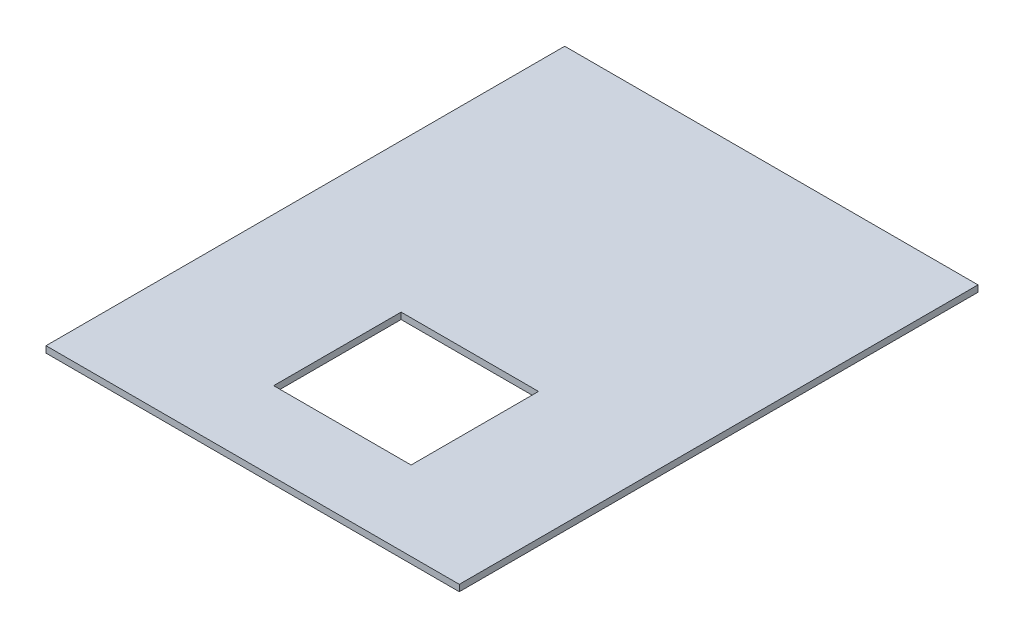
from build123d import *

# Parameters (mm, degrees)
SKETCH1_W           = 304.8
SKETCH1_H           = 382.524
SKETCH1_W_2         = 101.346
SKETCH1_H_2         = 93.98
BOSS_EXTRUDE1_DEPTH = 4.7625


with BuildPart() as part:
    # Sketch1 → Boss-Extrude1 (new body)
    with BuildSketch(Plane(origin=(0, 0, 0), x_dir=(1, 0, 0), z_dir=(0, 1, 0))):
        Rectangle(SKETCH1_W, SKETCH1_H)
        with Locations((7.747, -85.852)):
            Rectangle(SKETCH1_W_2, SKETCH1_H_2, mode=Mode.SUBTRACT)
    extrude(amount=BOSS_EXTRUDE1_DEPTH)


solid = part.part
